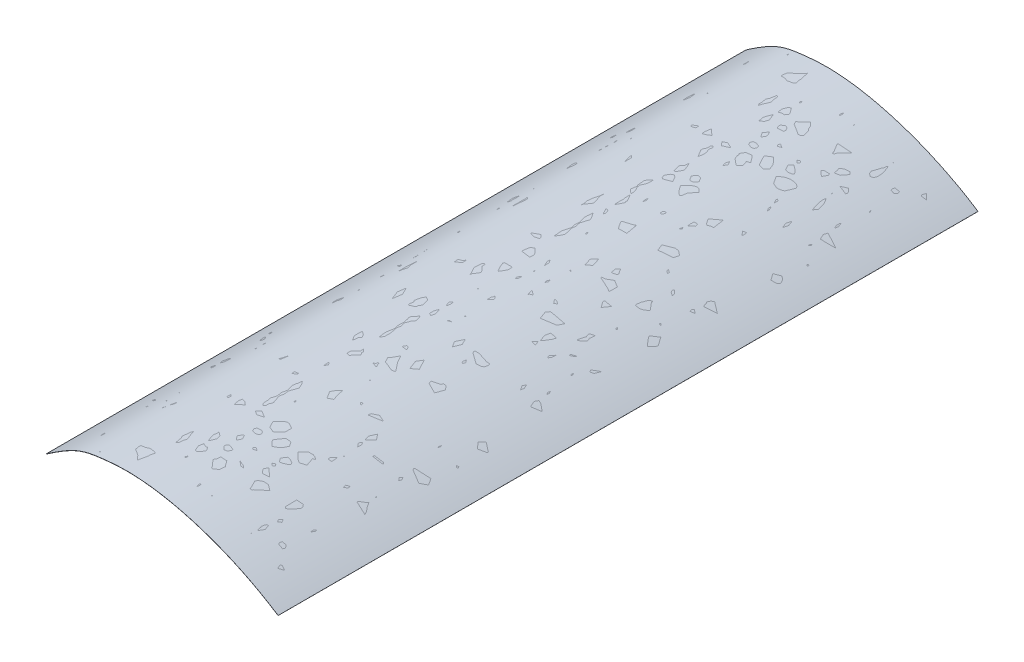
from build123d import *

# Parameters (mm, degrees)
BOSS_EXTRUDE1_DEPTH = 600.2


with BuildPart() as part:
    # Sketch1 → Boss-Extrude1 (new body)
    with BuildSketch(Plane.XY):
        with BuildLine():
            Line((-1743.664933471, 593.912653171), (-1743.607960183, 593.830470178))
            add(Edge.make_bspline(
                [(-1743.607960183, 593.830470178), (-1719.507904213, 610.537812828), (-1709.389541143, 613.399774739), (-1646.280289738, 619.241808081), (-1585.716648888, 600.423930323), (-1544.649956659, 573.44143308)],
                knots=[0, 0, 0, 0, 0.320554642, 0.420554642, 1, 1, 1, 1], degree=3))
            Line((-1544.649956659, 573.44143308), (-1544.595044821, 573.525007538))
            add(Edge.make_bspline(
                [(-1743.664933471, 593.912653171), (-1743.087942797, 594.31265145), (-1741.917203527, 595.120504528), (-1739.688491007, 596.64256443), (-1737.024222336, 598.431013991), (-1734.030056424, 600.386186826), (-1730.275006147, 602.758210899), (-1725.985083603, 605.304700102), (-1721.337743682, 607.7711254), (-1717.047071616, 609.727218927), (-1711.610414501, 611.760075968), (-1704.985540448, 613.422395736), (-1697.649002338, 614.432584074), (-1690.74433015, 615.188792173), (-1683.191728778, 615.856790836), (-1672.852283198, 616.250864323), (-1659.640242154, 615.52416439), (-1645.744138719, 613.708396811), (-1631.355030831, 610.827998004), (-1616.64523619, 606.93036839), (-1601.792074518, 602.056621703), (-1586.97193086, 596.249740218), (-1572.360160797, 589.551302581), (-1560.507806279, 583.263931197), (-1551.300823517, 577.826880634), (-1546.816908994, 574.984863218), (-1544.595044821, 573.525007538)],
                knots=[0, 0, 0, 0, 0.0078125, 0.015625, 0.03125, 0.046875, 0.0625, 0.09375, 0.125, 0.15625, 0.1875, 0.25, 0.3125, 0.34375, 0.375, 0.4375, 0.5, 0.5625, 0.625, 0.6875, 0.75, 0.8125, 0.875, 0.9375, 0.96875, 1, 1, 1, 1], degree=3))
        make_face()
    extrude(amount=BOSS_EXTRUDE1_DEPTH)


solid = part.part
